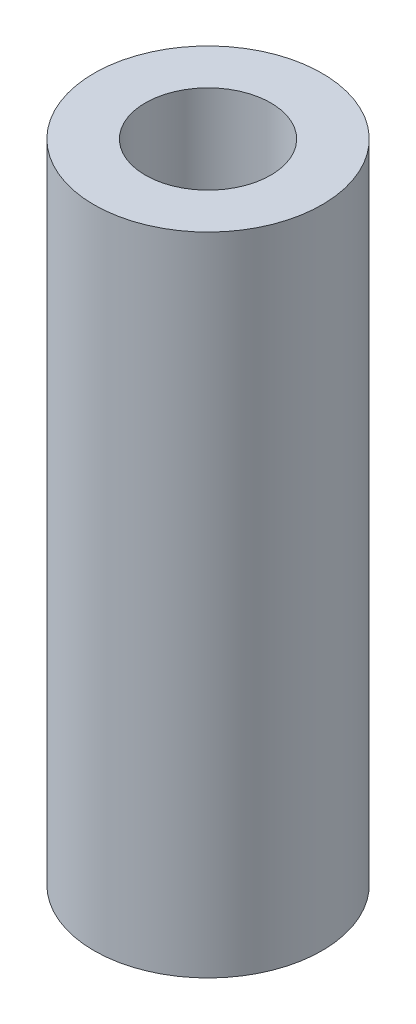
from build123d import *

# Parameters (mm, degrees)
SKETCH2_R           = 3
SKETCH2_R_2         = 1.65
BOSS_EXTRUDE1_DEPTH = 17


with BuildPart() as part:
    # Sketch2 → Boss-Extrude1 (new body)
    with BuildSketch(Plane(origin=(0, 143.565722281, 0), x_dir=(1, 0, 0), z_dir=(0, 1, 0))):
        with Locations((5.036862118, -260.757908841)):
            Circle(SKETCH2_R)
        with Locations((5.036862118, -260.757908841)):
            Circle(SKETCH2_R_2, mode=Mode.SUBTRACT)
    extrude(amount=BOSS_EXTRUDE1_DEPTH)


solid = part.part
